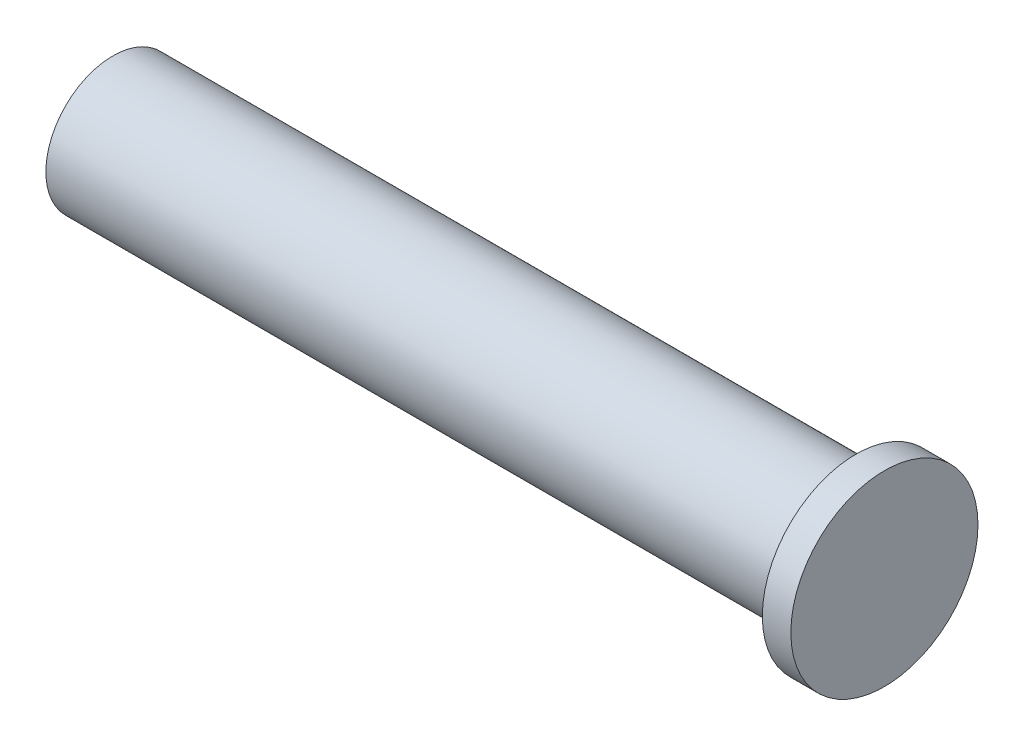
from build123d import *


with BuildPart() as part:
    # Sketch2 → Revolve1 (revolve)
    with BuildSketch(Plane(origin=(0, 0, 0), x_dir=(1, 0, 0), z_dir=(0, 1, 0))):
        Polygon((-22.6695, -3.937), (20.9931, -3.937), (20.9931, -5.4991), (22.6695, -5.4991), (22.6695, 0), (-22.6695, 0), align=None)
    revolve(axis=Axis((22.6695, 0, 0), (-1, 0, 0)))


solid = part.part
